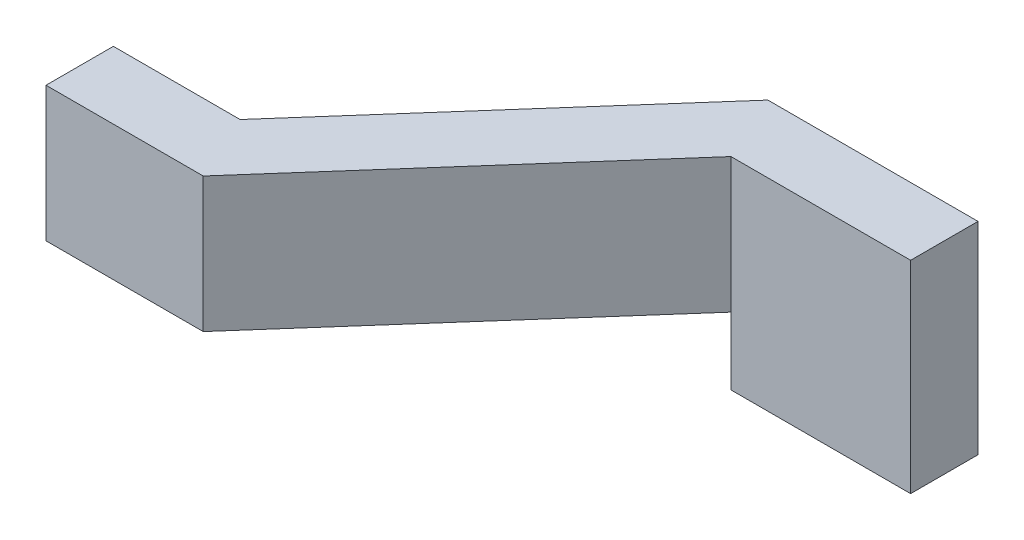
from build123d import *

# Parameters (mm, degrees)
BOSS_EXTRUDE1_DEPTH = 0.762
SKETCH2_W           = 2.286
SKETCH2_H           = 0.381
CUT_EXTRUDE1_DEPTH  = 2.9685
SKETCH4_W           = 1.016
SKETCH4_H           = 0.381
CUT_EXTRUDE3_DEPTH  = 2.9685


with BuildPart() as part:
    # Sketch1 → Boss-Extrude1 (new body, symmetric)
    with BuildSketch(Plane(origin=(0, 0, 0), x_dir=(1, 0, 0), z_dir=(0, 1, 0))):
        Polygon((0, 0), (0.889, 0), (2.286, 1.5875), (3.302, 1.5875), (3.302, 1.9685), (2.113762829, 1.9685), (0.716762829, 0.381), (0, 0.381), align=None)
    extrude(amount=BOSS_EXTRUDE1_DEPTH, both=True)

    # Sketch2 → Cut-Extrude1 (cut, through all)
    with BuildSketch(Plane(origin=(0, 0, -1.9685), x_dir=(-1, 0, 0), z_dir=(0, 0, -1))):
        with Locations((-1.143, 0.5715)):
            Rectangle(SKETCH2_W, SKETCH2_H)
    cut_extrude1 = extrude(amount=-CUT_EXTRUDE1_DEPTH, mode=Mode.SUBTRACT)

    # Mirror1: Cut-Extrude1 across plane
    add(cut_extrude1.mirror(Plane.ZX), mode=Mode.SUBTRACT)

    # Sketch4 → Cut-Extrude3 (cut, through all)
    with BuildSketch(Plane(origin=(0, 0, -1.9685), x_dir=(-1, 0, 0), z_dir=(0, 0, -1))):
        with Locations((-2.794, 0.5715)):
            Rectangle(SKETCH4_W, SKETCH4_H)
    extrude(amount=-CUT_EXTRUDE3_DEPTH, mode=Mode.SUBTRACT)


solid = part.part
